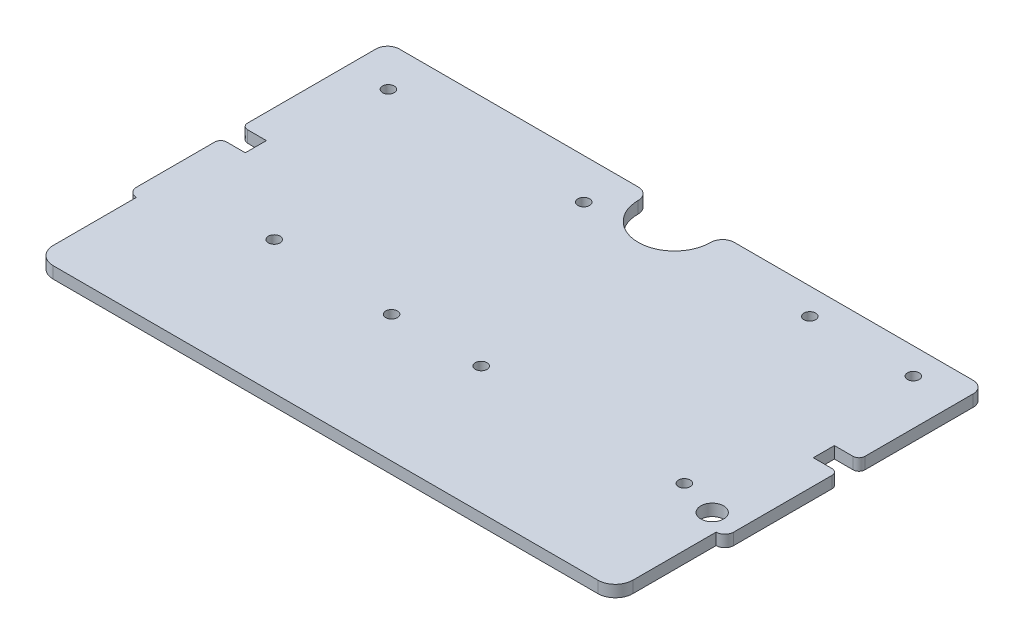
from build123d import *

# Parameters (mm, degrees)
BOSS_EXTRUDE1_DEPTH     = 1
SKETCH2_W               = 2.1
SKETCH2_H               = 1.8
CUT_EXTRUDE1_DEPTH      = 1
CUT_EXTRUDE1_DEPTH_BACK = 2
FILLET1_R               = 0.5
SKETCH3_R               = 0.5
SKETCH3_R_2             = 0.975
CUT_EXTRUDE2_DEPTH      = 1
CUT_EXTRUDE2_DEPTH_BACK = 2


with BuildPart() as part:
    # Sketch1 → Boss-Extrude1 (new body)
    with BuildSketch(Plane(origin=(0, 0, 0), x_dir=(1, 0, 0), z_dir=(0, 1, 0))):
        with BuildLine():
            Line((0, -1), (0, -21.45))
            ThreePointArc((0, -21.45), (0.219669914, -21.980330086), (0.75, -22.2))
            Line((0.75, -22.2), (0.75, -29.3))
            ThreePointArc((0.75, -29.3), (1.189339828, -30.360660172), (2.25, -30.8))
            Line((2.25, -30.8), (48.75, -30.8))
            ThreePointArc((48.75, -30.8), (49.810660172, -30.360660172), (50.25, -29.3))
            Line((50.25, -29.3), (50.25, -22.2))
            ThreePointArc((50.25, -22.2), (50.780330086, -21.980330086), (51, -21.45))
            Line((51, -21.45), (51, -1))
            ThreePointArc((51, -1), (50.707106781, -0.292893219), (50, 0))
            Line((50, 0), (1, 0))
            ThreePointArc((1, 0), (0.292893219, -0.292893219), (0, -1))
        make_face()
    extrude(amount=BOSS_EXTRUDE1_DEPTH)

    # Sketch2 → Cut-Extrude1 (cut, two sides)
    with BuildSketch(Plane(origin=(0, 1, 0), x_dir=(1, 0, 0), z_dir=(0, 1, 0))) as cut_extrude1_sk:
        with Locations((1.05, -13.35)):
            Rectangle(SKETCH2_W, SKETCH2_H)
        with BuildLine():
            Line((29.6, 0), (21.4, 0))
            ThreePointArc((21.4, 0), (22.107106781, -0.292893219), (22.4, -1))
            ThreePointArc((22.4, -1), (25.5, -4.1), (28.6, -1))
            ThreePointArc((28.6, -1), (28.892893219, -0.292893219), (29.6, 0))
        make_face()
        with Locations((49.95, -11.65)):
            Rectangle(SKETCH2_W, SKETCH2_H)
    extrude(amount=CUT_EXTRUDE1_DEPTH, mode=Mode.SUBTRACT)
    extrude(cut_extrude1_sk.sketch, amount=-CUT_EXTRUDE1_DEPTH_BACK, mode=Mode.SUBTRACT)

    # Fillet1
    fillet1_edges = [part.edges().sort_by_distance(p)[0] for p in [
        (0, 0.5, 14.25),
        (0, 0.5, 12.45),
        (51, 0.5, 10.75),
        (51, 0.5, 12.55),
    ]]
    fillet(fillet1_edges, radius=FILLET1_R)

    # Sketch3 → Cut-Extrude2 (cut, two sides)
    with BuildSketch(Plane(origin=(0, 1, 0), x_dir=(1, 0, 0), z_dir=(0, 1, 0))) as cut_extrude2_sk:
        with Locations((3.52, -3.45)):
            Circle(SKETCH3_R)
        with Locations((20.2, -3.45)):
            Circle(SKETCH3_R)
        with Locations((38.3, -2.25)):
            Circle(SKETCH3_R)
        with Locations((47.14, -2.25)):
            Circle(SKETCH3_R)
        with Locations((48.627, -20.91)):
            Circle(SKETCH3_R_2)
        with Locations((45.29, -19.95)):
            Circle(SKETCH3_R)
        with Locations((27.94, -19.95)):
            Circle(SKETCH3_R)
        with Locations((20.29, -19.95)):
            Circle(SKETCH3_R)
        with Locations((9.75, -19.43)):
            Circle(SKETCH3_R)
    extrude(amount=CUT_EXTRUDE2_DEPTH, mode=Mode.SUBTRACT)
    extrude(cut_extrude2_sk.sketch, amount=-CUT_EXTRUDE2_DEPTH_BACK, mode=Mode.SUBTRACT)


solid = part.part
